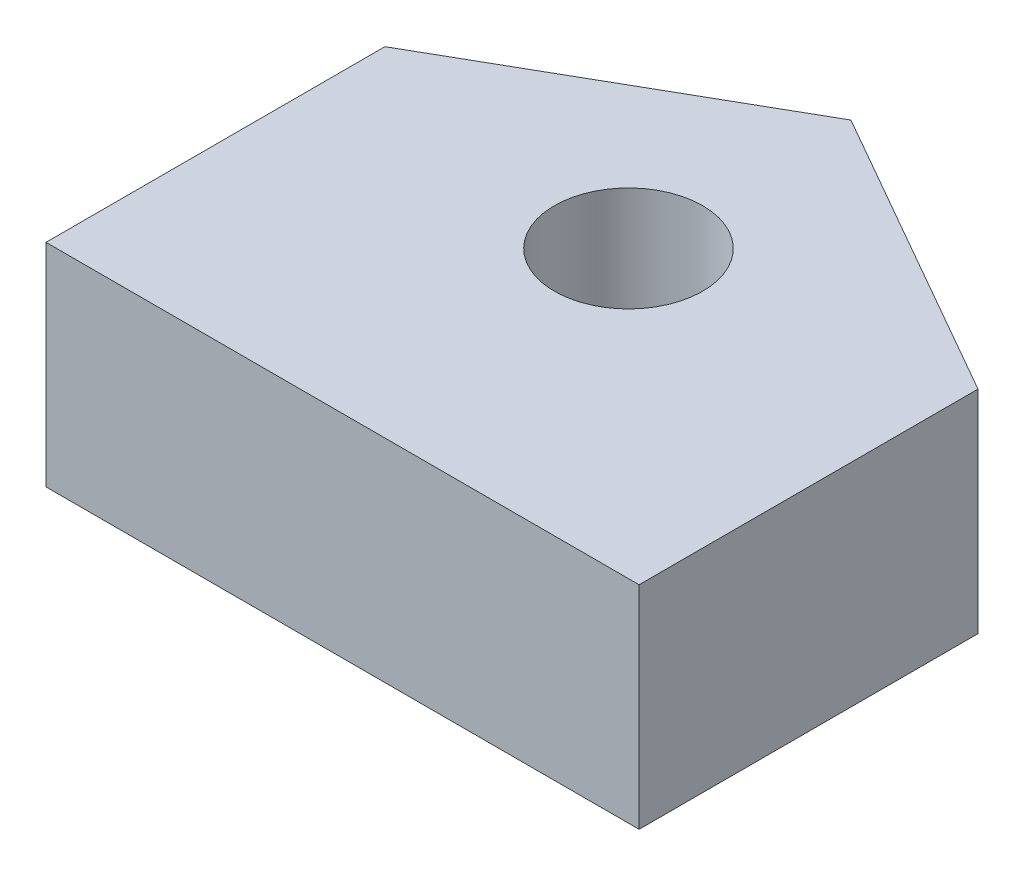
from build123d import *

# Parameters (mm, degrees)
SKETCH2_R           = 1.75
BOSS_EXTRUDE3_DEPTH = 5


with BuildPart() as part:
    # Sketch2 → Boss-Extrude3 (new body)
    with BuildSketch(Plane(origin=(0, 0, 0), x_dir=(1, 0, 0), z_dir=(0, 1, 0))):
        Polygon((-268, -48.75), (-268, -56.75), (-254, -56.75), (-254, -48.75), (-261, -44.75), align=None)
        with Locations((-261, -50)):
            Circle(SKETCH2_R, mode=Mode.SUBTRACT)
    extrude(amount=BOSS_EXTRUDE3_DEPTH)


solid = part.part
